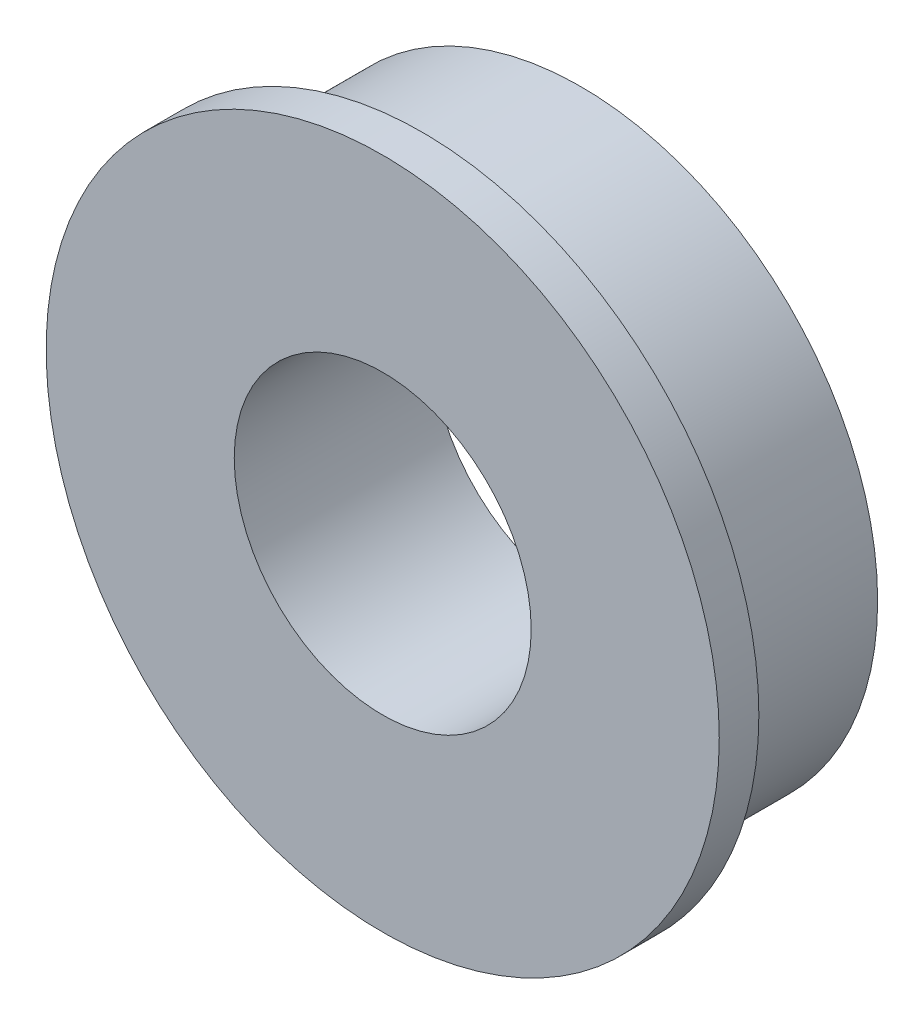
from build123d import *

# Parameters (mm, degrees)
SKETCH_1_R          = 6
SKETCH_1_R_2        = 3
EXTRUDE_1_DEPTH     = 3.2
SKETCH_2_R          = 6.8
EXTRUDE_2_DEPTH     = 0.8
SKETCH_3_R          = 3
CUT_EXTRUDE_1_DEPTH = 0.8


with BuildPart() as part:
    # 草图1 → 凸台-拉伸1 (new body)
    with BuildSketch(Plane.XY):
        Circle(SKETCH_1_R)
        Circle(SKETCH_1_R_2, mode=Mode.SUBTRACT)
    extrude(amount=EXTRUDE_1_DEPTH)

    # 草图2 → 凸台-拉伸2 (add)
    with BuildSketch(Plane.XY.offset(3.2)):
        Circle(SKETCH_2_R)
    extrude(amount=EXTRUDE_2_DEPTH)

    # 草图3 → 切除-拉伸1 (cut)
    with BuildSketch(Plane(origin=(0, 0, 3.2), x_dir=(-1, 0, 0), z_dir=(0, 0, -1))):
        Circle(SKETCH_3_R)
    extrude(amount=-CUT_EXTRUDE_1_DEPTH, mode=Mode.SUBTRACT)


solid = part.part
